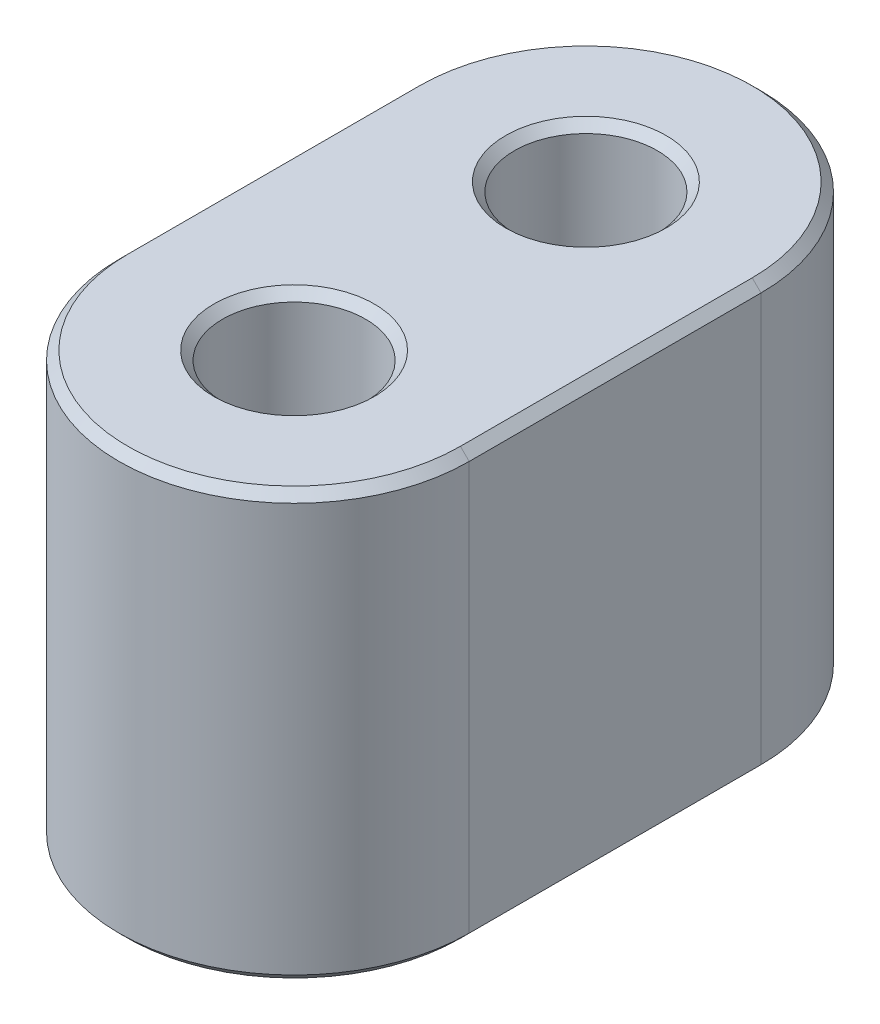
from build123d import *

# Parameters (mm, degrees)
SKETCH1_R           = 2.45
BOSS_EXTRUDE1_DEPTH = 14.6
CHAMFER1_SIZE       = 0.3


with BuildPart() as part:
    # Sketch1 → Boss-Extrude1 (new body)
    with BuildSketch(Plane(origin=(0, 0, 0), x_dir=(1, 0, 0), z_dir=(0, 1, 0))):
        with BuildLine():
            Line((-6, 0), (-6, 10))
            ThreePointArc((-6, 10), (0, 16), (6, 10))
            Line((6, 10), (6, 0))
            ThreePointArc((6, 0), (0, -6), (-6, 0))
        make_face()
        Circle(SKETCH1_R, mode=Mode.SUBTRACT)
        with Locations((0, 10)):
            Circle(SKETCH1_R, mode=Mode.SUBTRACT)
    extrude(amount=BOSS_EXTRUDE1_DEPTH)

    # Chamfer1
    chamfer1_edges = [part.edges().sort_by_distance(p)[0] for p in [
        (-2.45, 0, 0),
        (-2.45, 14.6, 0),
        (0, 14.6, -16),
        (-2.45, 0, -10),
        (-2.45, 14.6, -10),
        (-6, 14.6, -5),
        (0, 14.6, 6),
        (-6, 0, -5),
        (0, 0, -16),
        (6, 0, -5),
        (0, 0, 6),
        (6, 14.6, -5),
    ]]
    chamfer(chamfer1_edges, length=CHAMFER1_SIZE)


solid = part.part
